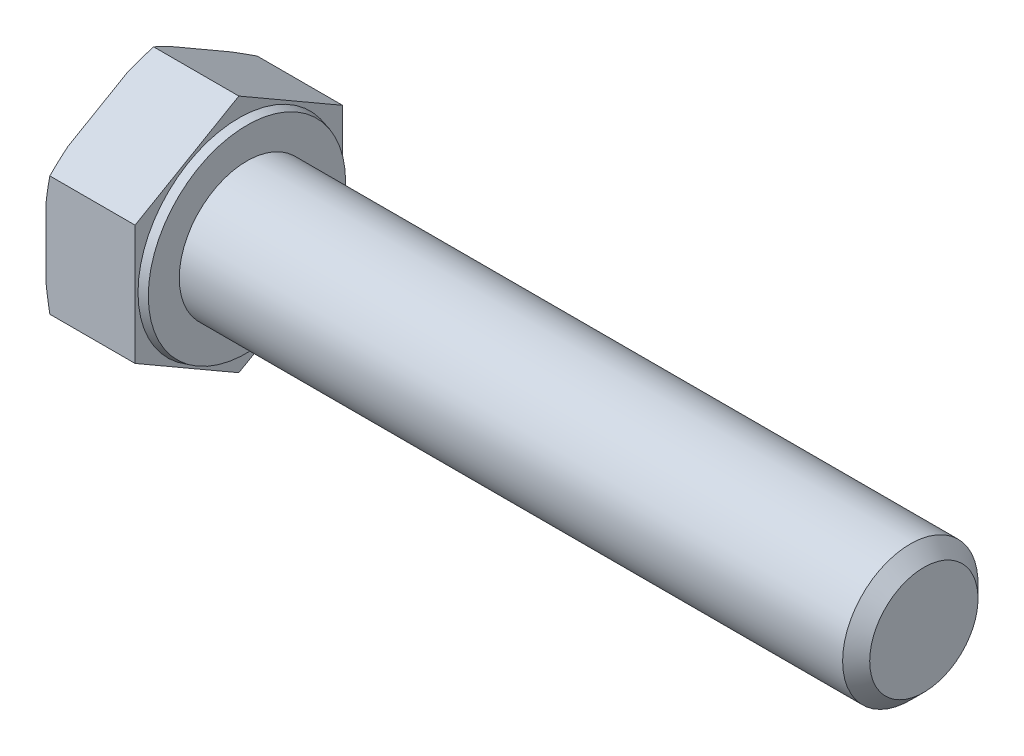
from build123d import *

# Parameters (mm, degrees)
SKETCH_2_OUTSIDE_W  = 32.184
SKETCH_2_OUTSIDE_H  = 32.184
CUT_EXTRUDE_1_DEPTH = 59.533728738
CHAMFER_1_SIZE      = 1


with BuildPart() as part:
    # Эскиз1 → Повернуть1 (revolve)
    with BuildSketch(Plane.XY, mode=Mode.PRIVATE) as revolve_1_sk:
        Polygon((-6.58, 0), (-6.58, 8.85), (0, 8.85), (0, 7.448974596), (0.6, 7.288205081), (0.6, 5), (50.6, 5), (50.6, 0), align=None)
    revolve(revolve_1_sk.sketch.rotate(Axis((-1000, 0, 0), (1, 0, 0)), 90), axis=Axis((-1000, 0, 0), (1, 0, 0)))

    # Эскиз2 outside → Вырез-Вытянуть1 (cut, through all)
    with BuildSketch(Plane.ZY.offset(6.58)):
        Rectangle(SKETCH_2_OUTSIDE_W, SKETCH_2_OUTSIDE_H)
        Polygon((0, -8.85), (7.664324823, -4.425), (7.664324823, 4.425), (0, 8.85), (-7.664324823, 4.425), (-7.664324823, -4.425), align=None, mode=Mode.SUBTRACT)
    extrude(amount=-CUT_EXTRUDE_1_DEPTH, mode=Mode.SUBTRACT)

    # Эскиз4 → Вырез-Повернуть1 (revolve, cut)
    with BuildSketch(Plane.XY):
        Polygon((-6.58, 8.075), (-6.297923068, 8.85), (-6.58, 8.85), align=None)
    revolve(axis=Axis((-1000, 0, 0), (1, 0, 0)), mode=Mode.SUBTRACT)

    # Фаска1
    chamfer_1_edges = [part.edges().sort_by_distance(p)[0] for p in [
        (50.6, 0, -5),
    ]]
    chamfer(chamfer_1_edges, length=CHAMFER_1_SIZE)


solid = part.part
